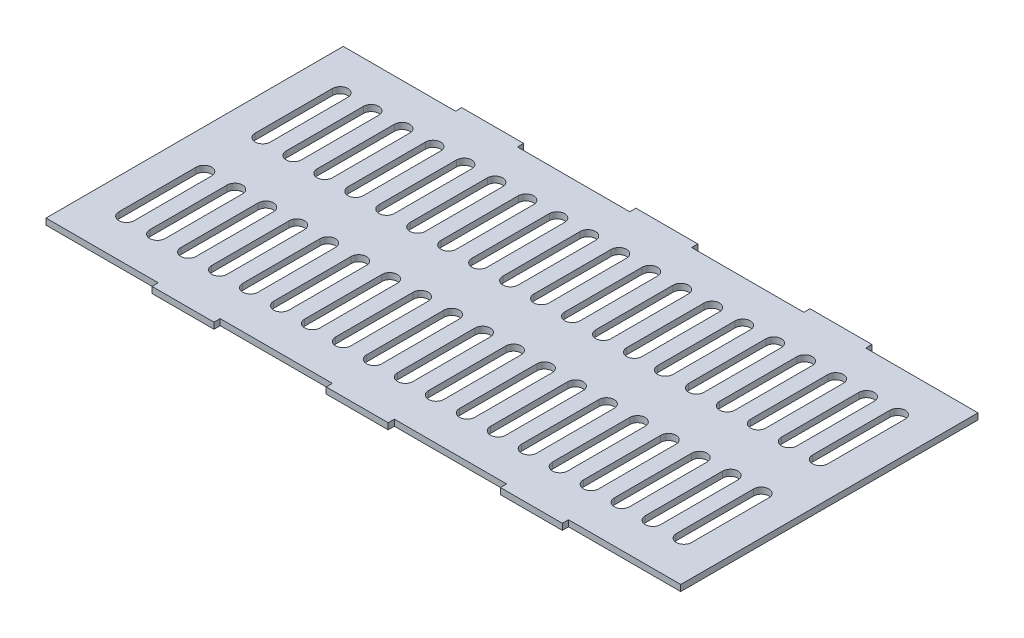
from build123d import *

# Parameters (mm, degrees)
SKETCH1_W           = 245
SKETCH1_H           = 96
BOSS_EXTRUDE1_DEPTH = 2
SKETCH4_W           = 40.020423845
SKETCH4_H           = 96
CUT_EXTRUDE2_DEPTH  = 10
SKETCH7_W           = 20
SKETCH7_H           = 2
BOSS_EXTRUDE2_DEPTH = 2
SKETCH10_W          = 20
SKETCH10_H          = 2
SKETCH10_W_2        = 19.999740207
BOSS_EXTRUDE4_DEPTH = 2


with BuildPart() as part:
    # Sketch1 → Boss-Extrude1 (new body)
    with BuildSketch(Plane(origin=(0, 0, 0), x_dir=(1, 0, 0), z_dir=(0, 1, 0))):
        with Locations((-141.622031913, 40.09002746)):
            Rectangle(SKETCH1_W, SKETCH1_H)
    extrude(amount=BOSS_EXTRUDE1_DEPTH)

    # Sketch4 → Cut-Extrude2 (cut)
    with BuildSketch(Plane(origin=(0, 2, 0), x_dir=(1, 0, 0), z_dir=(0, 1, 0))):
        with BuildLine():
            Line((-249.142455758, 30.59002746), (-249.142455758, 5.59002746))
            ThreePointArc((-249.142455758, 5.59002746), (-251.622031913, 3.110451305), (-254.101608068, 5.59002746))
            Line((-254.101608068, 5.59002746), (-254.101608068, 30.59002746))
            ThreePointArc((-254.101608068, 30.59002746), (-251.622031913, 33.069603615), (-249.142455758, 30.59002746))
        make_face()
        with BuildLine():
            Line((-244.101608068, 30.59002746), (-244.101608068, 5.59002746))
            ThreePointArc((-244.101608068, 5.59002746), (-241.622031913, 3.110451305), (-239.142455758, 5.59002746))
            Line((-239.142455758, 5.59002746), (-239.142455758, 30.59002746))
            ThreePointArc((-239.142455758, 30.59002746), (-241.622031913, 33.069603615), (-244.101608068, 30.59002746))
        make_face()
        with BuildLine():
            Line((-234.101608068, 30.59002746), (-234.101608068, 5.59002746))
            ThreePointArc((-234.101608068, 5.59002746), (-231.622031913, 3.110451305), (-229.142455758, 5.59002746))
            Line((-229.142455758, 5.59002746), (-229.142455758, 30.59002746))
            ThreePointArc((-229.142455758, 30.59002746), (-231.622031913, 33.069603615), (-234.101608068, 30.59002746))
        make_face()
        with BuildLine():
            Line((-224.101608068, 30.59002746), (-224.101608068, 5.59002746))
            ThreePointArc((-224.101608068, 5.59002746), (-221.622031913, 3.110451305), (-219.142455758, 5.59002746))
            Line((-219.142455758, 5.59002746), (-219.142455758, 30.59002746))
            ThreePointArc((-219.142455758, 30.59002746), (-221.622031913, 33.069603615), (-224.101608068, 30.59002746))
        make_face()
        with BuildLine():
            Line((-214.101608068, 30.59002746), (-214.101608068, 5.59002746))
            ThreePointArc((-214.101608068, 5.59002746), (-211.622031913, 3.110451305), (-209.142455758, 5.59002746))
            Line((-209.142455758, 5.59002746), (-209.142455758, 30.59002746))
            ThreePointArc((-209.142455758, 30.59002746), (-211.622031913, 33.069603615), (-214.101608068, 30.59002746))
        make_face()
        with BuildLine():
            Line((-204.101608068, 30.59002746), (-204.101608068, 5.59002746))
            ThreePointArc((-204.101608068, 5.59002746), (-201.622031913, 3.110451305), (-199.142455758, 5.59002746))
            Line((-199.142455758, 5.59002746), (-199.142455758, 30.59002746))
            ThreePointArc((-199.142455758, 30.59002746), (-201.622031913, 33.069603615), (-204.101608068, 30.59002746))
        make_face()
        with BuildLine():
            Line((-194.101608068, 30.59002746), (-194.101608068, 5.59002746))
            ThreePointArc((-194.101608068, 5.59002746), (-191.622031913, 3.110451305), (-189.142455758, 5.59002746))
            Line((-189.142455758, 5.59002746), (-189.142455758, 30.59002746))
            ThreePointArc((-189.142455758, 30.59002746), (-191.622031913, 33.069603615), (-194.101608068, 30.59002746))
        make_face()
        with BuildLine():
            Line((-184.101608068, 30.59002746), (-184.101608068, 5.59002746))
            ThreePointArc((-184.101608068, 5.59002746), (-181.622031913, 3.110451305), (-179.142455758, 5.59002746))
            Line((-179.142455758, 5.59002746), (-179.142455758, 30.59002746))
            ThreePointArc((-179.142455758, 30.59002746), (-181.622031913, 33.069603615), (-184.101608068, 30.59002746))
        make_face()
        with BuildLine():
            Line((-174.101608068, 30.59002746), (-174.101608068, 5.59002746))
            ThreePointArc((-174.101608068, 5.59002746), (-171.622031913, 3.110451305), (-169.142455758, 5.59002746))
            Line((-169.142455758, 5.59002746), (-169.142455758, 30.59002746))
            ThreePointArc((-169.142455758, 30.59002746), (-171.622031913, 33.069603615), (-174.101608068, 30.59002746))
        make_face()
        with BuildLine():
            Line((-164.101608068, 30.59002746), (-164.101608068, 5.59002746))
            ThreePointArc((-164.101608068, 5.59002746), (-161.622031913, 3.110451305), (-159.142455758, 5.59002746))
            Line((-159.142455758, 5.59002746), (-159.142455758, 30.59002746))
            ThreePointArc((-159.142455758, 30.59002746), (-161.622031913, 33.069603615), (-164.101608068, 30.59002746))
        make_face()
        with BuildLine():
            Line((-154.101608068, 30.59002746), (-154.101608068, 5.59002746))
            ThreePointArc((-154.101608068, 5.59002746), (-151.622031913, 3.110451305), (-149.142455758, 5.59002746))
            Line((-149.142455758, 5.59002746), (-149.142455758, 30.59002746))
            ThreePointArc((-149.142455758, 30.59002746), (-151.622031913, 33.069603615), (-154.101608068, 30.59002746))
        make_face()
        with BuildLine():
            Line((-144.101608068, 30.59002746), (-144.101608068, 5.59002746))
            ThreePointArc((-144.101608068, 5.59002746), (-141.622031913, 3.110451305), (-139.142455758, 5.59002746))
            Line((-139.142455758, 5.59002746), (-139.142455758, 30.59002746))
            ThreePointArc((-139.142455758, 30.59002746), (-141.622031913, 33.069603615), (-144.101608068, 30.59002746))
        make_face()
        with BuildLine():
            Line((-134.101608068, 30.59002746), (-134.101608068, 5.59002746))
            ThreePointArc((-134.101608068, 5.59002746), (-131.622031913, 3.110451305), (-129.142455758, 5.59002746))
            Line((-129.142455758, 5.59002746), (-129.142455758, 30.59002746))
            ThreePointArc((-129.142455758, 30.59002746), (-131.622031913, 33.069603615), (-134.101608068, 30.59002746))
        make_face()
        with BuildLine():
            Line((-124.101608068, 30.59002746), (-124.101608068, 5.59002746))
            ThreePointArc((-124.101608068, 5.59002746), (-121.622031913, 3.110451305), (-119.142455758, 5.59002746))
            Line((-119.142455758, 5.59002746), (-119.142455758, 30.59002746))
            ThreePointArc((-119.142455758, 30.59002746), (-121.622031913, 33.069603615), (-124.101608068, 30.59002746))
        make_face()
        with BuildLine():
            Line((-119.142455758, 49.59002746), (-119.142455758, 74.59002746))
            ThreePointArc((-119.142455758, 74.59002746), (-121.622031913, 77.069603615), (-124.101608068, 74.59002746))
            Line((-124.101608068, 74.59002746), (-124.101608068, 49.59002746))
            ThreePointArc((-124.101608068, 49.59002746), (-121.622031913, 47.110451305), (-119.142455758, 49.59002746))
        make_face()
        with BuildLine():
            Line((-129.142455758, 49.59002746), (-129.142455758, 74.59002746))
            ThreePointArc((-129.142455758, 74.59002746), (-131.622031913, 77.069603615), (-134.101608068, 74.59002746))
            Line((-134.101608068, 74.59002746), (-134.101608068, 49.59002746))
            ThreePointArc((-134.101608068, 49.59002746), (-131.622031913, 47.110451305), (-129.142455758, 49.59002746))
        make_face()
        with BuildLine():
            Line((-139.142455758, 49.59002746), (-139.142455758, 74.59002746))
            ThreePointArc((-139.142455758, 74.59002746), (-141.622031913, 77.069603615), (-144.101608068, 74.59002746))
            Line((-144.101608068, 74.59002746), (-144.101608068, 49.59002746))
            ThreePointArc((-144.101608068, 49.59002746), (-141.622031913, 47.110451305), (-139.142455758, 49.59002746))
        make_face()
        with BuildLine():
            Line((-149.142455758, 49.59002746), (-149.142455758, 74.59002746))
            ThreePointArc((-149.142455758, 74.59002746), (-151.622031913, 77.069603615), (-154.101608068, 74.59002746))
            Line((-154.101608068, 74.59002746), (-154.101608068, 49.59002746))
            ThreePointArc((-154.101608068, 49.59002746), (-151.622031913, 47.110451305), (-149.142455758, 49.59002746))
        make_face()
        with BuildLine():
            Line((-159.142455758, 49.59002746), (-159.142455758, 74.59002746))
            ThreePointArc((-159.142455758, 74.59002746), (-161.622031913, 77.069603615), (-164.101608068, 74.59002746))
            Line((-164.101608068, 74.59002746), (-164.101608068, 49.59002746))
            ThreePointArc((-164.101608068, 49.59002746), (-161.622031913, 47.110451305), (-159.142455758, 49.59002746))
        make_face()
        with BuildLine():
            Line((-169.142455758, 49.59002746), (-169.142455758, 74.59002746))
            ThreePointArc((-169.142455758, 74.59002746), (-171.622031913, 77.069603615), (-174.101608068, 74.59002746))
            Line((-174.101608068, 74.59002746), (-174.101608068, 49.59002746))
            ThreePointArc((-174.101608068, 49.59002746), (-171.622031913, 47.110451305), (-169.142455758, 49.59002746))
        make_face()
        with BuildLine():
            Line((-179.142455758, 49.59002746), (-179.142455758, 74.59002746))
            ThreePointArc((-179.142455758, 74.59002746), (-181.622031913, 77.069603615), (-184.101608068, 74.59002746))
            Line((-184.101608068, 74.59002746), (-184.101608068, 49.59002746))
            ThreePointArc((-184.101608068, 49.59002746), (-181.622031913, 47.110451305), (-179.142455758, 49.59002746))
        make_face()
        with BuildLine():
            Line((-189.142455758, 49.59002746), (-189.142455758, 74.59002746))
            ThreePointArc((-189.142455758, 74.59002746), (-191.622031913, 77.069603615), (-194.101608068, 74.59002746))
            Line((-194.101608068, 74.59002746), (-194.101608068, 49.59002746))
            ThreePointArc((-194.101608068, 49.59002746), (-191.622031913, 47.110451305), (-189.142455758, 49.59002746))
        make_face()
        with BuildLine():
            Line((-199.142455758, 49.59002746), (-199.142455758, 74.59002746))
            ThreePointArc((-199.142455758, 74.59002746), (-201.622031913, 77.069603615), (-204.101608068, 74.59002746))
            Line((-204.101608068, 74.59002746), (-204.101608068, 49.59002746))
            ThreePointArc((-204.101608068, 49.59002746), (-201.622031913, 47.110451305), (-199.142455758, 49.59002746))
        make_face()
        with BuildLine():
            Line((-209.142455758, 49.59002746), (-209.142455758, 74.59002746))
            ThreePointArc((-209.142455758, 74.59002746), (-211.622031913, 77.069603615), (-214.101608068, 74.59002746))
            Line((-214.101608068, 74.59002746), (-214.101608068, 49.59002746))
            ThreePointArc((-214.101608068, 49.59002746), (-211.622031913, 47.110451305), (-209.142455758, 49.59002746))
        make_face()
        with BuildLine():
            Line((-219.142455758, 49.59002746), (-219.142455758, 74.59002746))
            ThreePointArc((-219.142455758, 74.59002746), (-221.622031913, 77.069603615), (-224.101608068, 74.59002746))
            Line((-224.101608068, 74.59002746), (-224.101608068, 49.59002746))
            ThreePointArc((-224.101608068, 49.59002746), (-221.622031913, 47.110451305), (-219.142455758, 49.59002746))
        make_face()
        with BuildLine():
            Line((-229.142455758, 49.59002746), (-229.142455758, 74.59002746))
            ThreePointArc((-229.142455758, 74.59002746), (-231.622031913, 77.069603615), (-234.101608068, 74.59002746))
            Line((-234.101608068, 74.59002746), (-234.101608068, 49.59002746))
            ThreePointArc((-234.101608068, 49.59002746), (-231.622031913, 47.110451305), (-229.142455758, 49.59002746))
        make_face()
        with BuildLine():
            Line((-239.142455758, 49.59002746), (-239.142455758, 74.59002746))
            ThreePointArc((-239.142455758, 74.59002746), (-241.622031913, 77.069603615), (-244.101608068, 74.59002746))
            Line((-244.101608068, 74.59002746), (-244.101608068, 49.59002746))
            ThreePointArc((-244.101608068, 49.59002746), (-241.622031913, 47.110451305), (-239.142455758, 49.59002746))
        make_face()
        with BuildLine():
            Line((-249.142455758, 49.59002746), (-249.142455758, 74.59002746))
            ThreePointArc((-249.142455758, 74.59002746), (-251.622031913, 77.069603615), (-254.101608068, 74.59002746))
            Line((-254.101608068, 74.59002746), (-254.101608068, 49.59002746))
            ThreePointArc((-254.101608068, 49.59002746), (-251.622031913, 47.110451305), (-249.142455758, 49.59002746))
        make_face()
        with BuildLine():
            Line((-109.142455758, 30.59002746), (-109.142455758, 5.59002746))
            ThreePointArc((-109.142455758, 5.59002746), (-111.622031913, 3.110451305), (-114.101608068, 5.59002746))
            Line((-114.101608068, 5.59002746), (-114.101608068, 30.59002746))
            ThreePointArc((-114.101608068, 30.59002746), (-111.622031913, 33.069603615), (-109.142455758, 30.59002746))
        make_face()
        with BuildLine():
            Line((-99.142455758, 30.59002746), (-99.142455758, 5.59002746))
            ThreePointArc((-99.142455758, 5.59002746), (-101.622031913, 3.110451305), (-104.101608068, 5.59002746))
            Line((-104.101608068, 5.59002746), (-104.101608068, 30.59002746))
            ThreePointArc((-104.101608068, 30.59002746), (-101.622031913, 33.069603615), (-99.142455758, 30.59002746))
        make_face()
        with BuildLine():
            Line((-89.142455758, 30.59002746), (-89.142455758, 5.59002746))
            ThreePointArc((-89.142455758, 5.59002746), (-91.622031913, 3.110451305), (-94.101608068, 5.59002746))
            Line((-94.101608068, 5.59002746), (-94.101608068, 30.59002746))
            ThreePointArc((-94.101608068, 30.59002746), (-91.622031913, 33.069603615), (-89.142455758, 30.59002746))
        make_face()
        with BuildLine():
            Line((-79.142455758, 30.59002746), (-79.142455758, 5.59002746))
            ThreePointArc((-79.142455758, 5.59002746), (-81.622031913, 3.110451305), (-84.101608068, 5.59002746))
            Line((-84.101608068, 5.59002746), (-84.101608068, 30.59002746))
            ThreePointArc((-84.101608068, 30.59002746), (-81.622031913, 33.069603615), (-79.142455758, 30.59002746))
        make_face()
        with BuildLine():
            Line((-69.142455758, 30.59002746), (-69.142455758, 5.59002746))
            ThreePointArc((-69.142455758, 5.59002746), (-71.622031913, 3.110451305), (-74.101608068, 5.59002746))
            Line((-74.101608068, 5.59002746), (-74.101608068, 30.59002746))
            ThreePointArc((-74.101608068, 30.59002746), (-71.622031913, 33.069603615), (-69.142455758, 30.59002746))
        make_face()
        with BuildLine():
            Line((-69.142455758, 49.59002746), (-69.142455758, 74.59002746))
            ThreePointArc((-69.142455758, 74.59002746), (-71.622031913, 77.069603615), (-74.101608068, 74.59002746))
            Line((-74.101608068, 74.59002746), (-74.101608068, 49.59002746))
            ThreePointArc((-74.101608068, 49.59002746), (-71.622031913, 47.110451305), (-69.142455758, 49.59002746))
        make_face()
        with BuildLine():
            Line((-79.142455758, 49.59002746), (-79.142455758, 74.59002746))
            ThreePointArc((-79.142455758, 74.59002746), (-81.622031913, 77.069603615), (-84.101608068, 74.59002746))
            Line((-84.101608068, 74.59002746), (-84.101608068, 49.59002746))
            ThreePointArc((-84.101608068, 49.59002746), (-81.622031913, 47.110451305), (-79.142455758, 49.59002746))
        make_face()
        with BuildLine():
            Line((-89.142455758, 49.59002746), (-89.142455758, 74.59002746))
            ThreePointArc((-89.142455758, 74.59002746), (-91.622031913, 77.069603615), (-94.101608068, 74.59002746))
            Line((-94.101608068, 74.59002746), (-94.101608068, 49.59002746))
            ThreePointArc((-94.101608068, 49.59002746), (-91.622031913, 47.110451305), (-89.142455758, 49.59002746))
        make_face()
        with BuildLine():
            Line((-99.142455758, 49.59002746), (-99.142455758, 74.59002746))
            ThreePointArc((-99.142455758, 74.59002746), (-101.622031913, 77.069603615), (-104.101608068, 74.59002746))
            Line((-104.101608068, 74.59002746), (-104.101608068, 49.59002746))
            ThreePointArc((-104.101608068, 49.59002746), (-101.622031913, 47.110451305), (-99.142455758, 49.59002746))
        make_face()
        with BuildLine():
            Line((-109.142455758, 49.59002746), (-109.142455758, 74.59002746))
            ThreePointArc((-109.142455758, 74.59002746), (-111.622031913, 77.069603615), (-114.101608068, 74.59002746))
            Line((-114.101608068, 74.59002746), (-114.101608068, 49.59002746))
            ThreePointArc((-114.101608068, 49.59002746), (-111.622031913, 47.110451305), (-109.142455758, 49.59002746))
        make_face()
        with Locations((-39.132243836, 40.09002746)):
            Rectangle(SKETCH4_W, SKETCH4_H)
    extrude(amount=-CUT_EXTRUDE2_DEPTH, mode=Mode.SUBTRACT)

    # Sketch7 → Boss-Extrude2 (add)
    with BuildSketch(Plane.XY.offset(7.90997254)):
        Polygon((-171.628639696, 2), (-171.628639696, 1), (-171.628639696, 0), (-151.628899489, 0), (-151.628899489, 2), align=None)
        with Locations((-105.385677623, 1)):
            Rectangle(SKETCH7_W, SKETCH7_H)
        with Locations((-217.875335804, 1)):
            Rectangle(SKETCH7_W, SKETCH7_H)
    extrude(amount=BOSS_EXTRUDE2_DEPTH)

    # Sketch10 → Boss-Extrude4 (add)
    with BuildSketch(Plane(origin=(0, 0, -88.09002746), x_dir=(-1, 0, 0), z_dir=(0, 0, -1))):
        with Locations((105.385677623, 1)):
            Rectangle(SKETCH10_W, SKETCH10_H)
        with Locations((161.628769593, 1)):
            Rectangle(SKETCH10_W_2, SKETCH10_H)
        with Locations((217.875335804, 1)):
            Rectangle(SKETCH10_W, SKETCH10_H)
    extrude(amount=BOSS_EXTRUDE4_DEPTH)


solid = part.part
